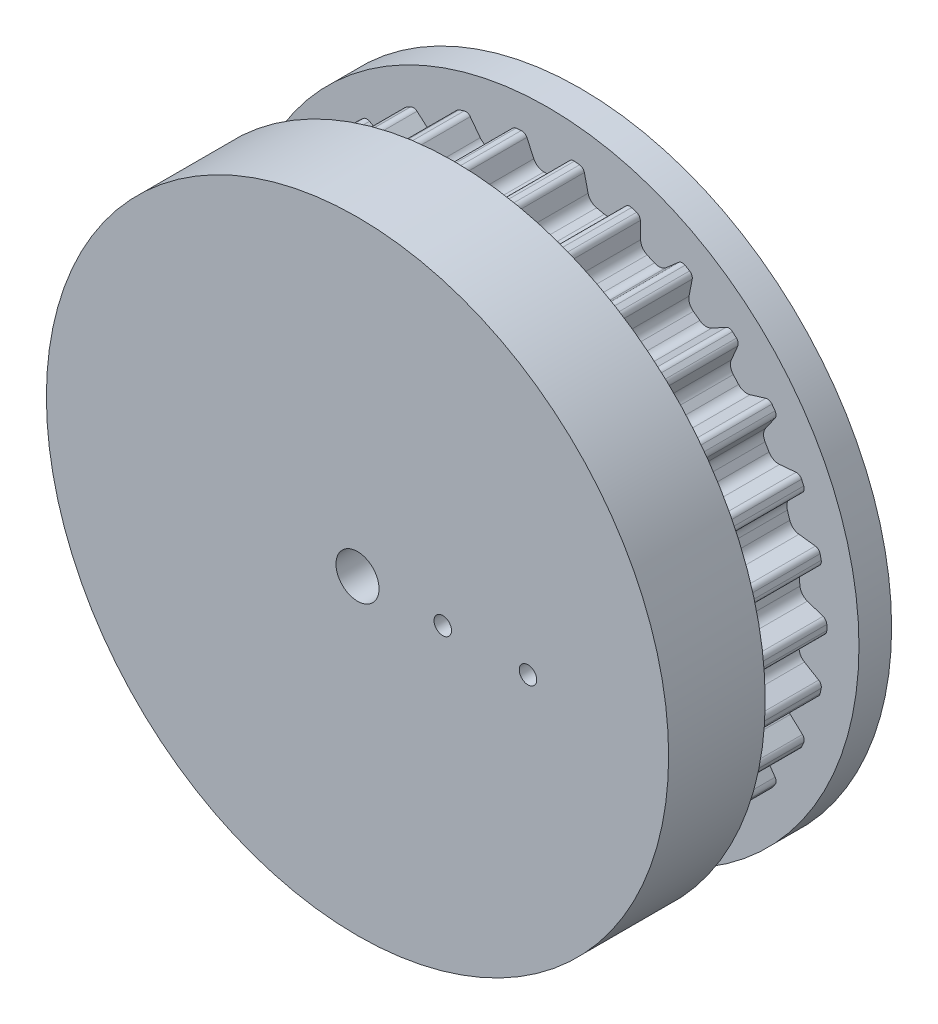
from build123d import *

# Parameters (mm, degrees)
CUT_EXTRUDE1_START       = 15.325
CUT_EXTRUDE1_DEPTH       = 37
FILLET2_R                = 1.298222222
FILLET1_R                = 2.596444444
CIRPATTERN1_COUNT        = 30
FILLET2_OF_CIRPATTERN1_R = 1.298222222
FILLET1_OF_CIRPATTERN1_R = 2.596444444
SKETCH5_R                = 22.54
CUT_EXTRUDE2_DEPTH       = 0.762
CUT_EXTRUDE3_START       = -0.762
SKETCH9_R                = 22.54
CUT_EXTRUDE3_DEPTH       = 0.762
SKETCH11_W               = 111
SKETCH11_H               = 6.35
CUT_EXTRUDE4_DEPTH       = 86.5
BOSS_EXTRUDE1_START      = -52.32
SKETCH12_R               = 20
BOSS_EXTRUDE1_DEPTH      = 52.32
SKETCH13_R               = 73
BOSS_EXTRUDE2_DEPTH      = 15
BOSS_EXTRUDE6_START      = 0.762
SKETCH19_R               = 22.54
SKETCH19_R_2             = 20
BOSS_EXTRUDE6_DEPTH      = 0.762
HOLE2_D                  = 10.1
CUT_EXTRUDE5_REACH       = 117.738
SKETCH22_R               = 2.05


with BuildPart() as part:
    # Sketch10 → Revolve1 (revolve)
    with BuildSketch(Plane(origin=(0, 0, 0), x_dir=(0, 0, -1), z_dir=(1, 0, 0)), mode=Mode.PRIVATE) as revolve1_sk:
        Polygon((-22.985, 20), (29.335, 20), (29.335, 73), (21.675, 73), (21.675, 65.445), (-15.325, 65.445), (-15.325, 73), (-22.985, 73), (-22.985, 55.5), (-29.335, 55.5), (-29.335, 20), align=None)
    revolve(revolve1_sk.sketch.rotate(Axis((0, 0, 22.985), (0, 0, -1)), 90), axis=Axis((0, 0, 22.985), (0, 0, -1)))

    # Sketch3 → Cut-Extrude1 (cut)
    with BuildSketch(Plane.XY.offset(CUT_EXTRUDE1_START)):
        with BuildLine():
            Line((-2.586739752, 59.387151992), (2.586739752, 59.387151992))
            Line((2.586739752, 59.387151992), (5.310909091, 65.229151992))
            ThreePointArc((5.310909091, 65.229151992), (0, 65.445), (-5.310909091, 65.229151992))
            Line((-5.310909091, 65.229151992), (-2.586739752, 59.387151992))
        make_face()
    cut_extrude1 = extrude(amount=-CUT_EXTRUDE1_DEPTH, mode=Mode.SUBTRACT)

    # Fillet2
    fillet2_edges = [part.edges().sort_by_distance(p)[0] for p in [
        (-5.310909091, 65.229151992, -3.175),
        (5.310909091, 65.229151992, -3.175),
    ]]
    fillet(fillet2_edges, radius=FILLET2_R)

    # Fillet1
    fillet1_edges = [part.edges().sort_by_distance(p)[0] for p in [
        (-2.586739752, 59.387151992, -3.175),
        (2.586739752, 59.387151992, -3.175),
    ]]
    fillet(fillet1_edges, radius=FILLET1_R)

    # CirPattern1: Cut-Extrude1 ×30 about axis
    cirpattern1_axis = Axis((0, 0, 0), (0, 0, 1))
    for i in range(1, CIRPATTERN1_COUNT):
        add(cut_extrude1.rotate(cirpattern1_axis, i * 360 / CIRPATTERN1_COUNT), mode=Mode.SUBTRACT)

    # Fillet2 of CirPattern1
    fillet2_of_cirpattern1_edges = [part.edges().sort_by_distance(p)[0] for p in [
        (-18.756756266, 62.69953843, -3.175),
        (-8.367050296, 64.907938608, -3.175),
        (-31.382843188, 57.429654173, -3.175),
        (-21.679329436, 61.749936844, -3.175),
        (-42.637349271, 49.64981845, -3.175),
        (-34.04411785, 55.89316653, -3.175),
        (-52.028398594, 39.700047415, -3.175),
        (-44.921014953, 47.593596634, -3.175),
        (-59.145557238, 28.015193806, -3.175),
        (-53.834648147, 37.213958186, -3.175),
        (-63.677771219, 15.105941796, -3.175),
        (-60.39544889, 25.207891193, -3.175),
        (-65.426961038, 1.536487643, -3.175),
        (-64.316678707, 12.100118393, -3.175),
        (-64.316678707, -12.100118393, -3.175),
        (-65.426961038, -1.536487643, -3.175),
        (-60.39544889, -25.207891193, -3.175),
        (-63.677771219, -15.105941796, -3.175),
        (-53.834648147, -37.213958186, -3.175),
        (-59.145557238, -28.015193806, -3.175),
        (-44.921014953, -47.593596634, -3.175),
        (-52.028398594, -39.700047415, -3.175),
        (-34.04411785, -55.89316653, -3.175),
        (-42.637349271, -49.64981845, -3.175),
        (-21.679329436, -61.749936844, -3.175),
        (-31.382843188, -57.429654173, -3.175),
        (-8.367050296, -64.907938608, -3.175),
        (-18.756756266, -62.69953843, -3.175),
        (5.310909091, -65.229151992, -3.175),
        (-5.310909091, -65.229151992, -3.175),
        (18.756756266, -62.69953843, -3.175),
        (8.367050296, -64.907938608, -3.175),
        (31.382843188, -57.429654173, -3.175),
        (21.679329436, -61.749936844, -3.175),
        (42.637349271, -49.64981845, -3.175),
        (34.04411785, -55.89316653, -3.175),
        (52.028398594, -39.700047415, -3.175),
        (44.921014953, -47.593596634, -3.175),
        (59.145557238, -28.015193806, -3.175),
        (53.834648147, -37.213958186, -3.175),
        (63.677771219, -15.105941796, -3.175),
        (60.39544889, -25.207891193, -3.175),
        (65.426961038, -1.536487643, -3.175),
        (64.316678707, -12.100118393, -3.175),
        (64.316678707, 12.100118393, -3.175),
        (65.426961038, 1.536487643, -3.175),
        (60.39544889, 25.207891193, -3.175),
        (63.677771219, 15.105941796, -3.175),
        (53.834648147, 37.213958186, -3.175),
        (59.145557238, 28.015193806, -3.175),
        (44.921014953, 47.593596634, -3.175),
        (52.028398594, 39.700047415, -3.175),
        (34.04411785, 55.89316653, -3.175),
        (42.637349271, 49.64981845, -3.175),
        (21.679329436, 61.749936844, -3.175),
        (31.382843188, 57.429654173, -3.175),
        (8.367050296, 64.907938608, -3.175),
        (18.756756266, 62.69953843, -3.175),
    ]]
    fillet(fillet2_of_cirpattern1_edges, radius=FILLET2_OF_CIRPATTERN1_R)

    # Fillet1 of CirPattern1
    fillet1_of_cirpattern1_edges = [part.edges().sort_by_distance(p)[0] for p in [
        (-14.877496466, 57.5515868, -3.175),
        (-9.817069901, 58.627213671, -3.175),
        (-26.518035194, 53.200741102, -3.175),
        (-21.791826493, 55.304984788, -3.175),
        (-36.999608536, 46.524767732, -3.175),
        (-32.814175697, 49.565662687, -3.175),
        (-45.864121442, 37.815438761, -3.175),
        (-42.402387964, 41.660083284, -3.175),
        (-52.72415216, 27.453393658, -3.175),
        (-50.137412408, 31.933758334, -3.175),
        (-57.27988443, 15.891503516, -3.175),
        (-55.681191343, 20.81177491, -3.175),
        (-59.332210891, 3.635078415, -3.175),
        (-58.791435029, 8.780217057, -3.175),
        (-58.791435029, -8.780217057, -3.175),
        (-59.332210891, -3.635078415, -3.175),
        (-55.681191343, -20.81177491, -3.175),
        (-57.27988443, -15.891503516, -3.175),
        (-50.137412408, -31.933758334, -3.175),
        (-52.72415216, -27.453393658, -3.175),
        (-42.402387964, -41.660083284, -3.175),
        (-45.864121442, -37.815438761, -3.175),
        (-32.814175697, -49.565662687, -3.175),
        (-36.999608536, -46.524767732, -3.175),
        (-21.791826493, -55.304984788, -3.175),
        (-26.518035194, -53.200741102, -3.175),
        (-9.817069901, -58.627213671, -3.175),
        (-14.877496466, -57.5515868, -3.175),
        (2.586739752, -59.387151992, -3.175),
        (-2.586739752, -59.387151992, -3.175),
        (14.877496466, -57.5515868, -3.175),
        (9.817069901, -58.627213671, -3.175),
        (26.518035194, -53.200741102, -3.175),
        (21.791826493, -55.304984788, -3.175),
        (36.999608536, -46.524767732, -3.175),
        (32.814175697, -49.565662687, -3.175),
        (45.864121442, -37.815438761, -3.175),
        (42.402387964, -41.660083284, -3.175),
        (52.72415216, -27.453393658, -3.175),
        (50.137412408, -31.933758334, -3.175),
        (57.27988443, -15.891503516, -3.175),
        (55.681191343, -20.81177491, -3.175),
        (59.332210891, -3.635078415, -3.175),
        (58.791435029, -8.780217057, -3.175),
        (58.791435029, 8.780217057, -3.175),
        (59.332210891, 3.635078415, -3.175),
        (55.681191343, 20.81177491, -3.175),
        (57.27988443, 15.891503516, -3.175),
        (50.137412408, 31.933758334, -3.175),
        (52.72415216, 27.453393658, -3.175),
        (42.402387964, 41.660083284, -3.175),
        (45.864121442, 37.815438761, -3.175),
        (32.814175697, 49.565662687, -3.175),
        (36.999608536, 46.524767732, -3.175),
        (21.791826493, 55.304984788, -3.175),
        (26.518035194, 53.200741102, -3.175),
        (9.817069901, 58.627213671, -3.175),
        (14.877496466, 57.5515868, -3.175),
    ]]
    fillet(fillet1_of_cirpattern1_edges, radius=FILLET1_OF_CIRPATTERN1_R)

    # Sketch5 → Cut-Extrude2 (cut)
    with BuildSketch(Plane.XY.offset(-29.335)):
        with Locations(Location((0, 0, 0), (0, 0, 180))):
            Circle(SKETCH5_R)
    extrude(amount=CUT_EXTRUDE2_DEPTH, mode=Mode.SUBTRACT)

    # Sketch9 → Cut-Extrude3 (cut)
    with BuildSketch(Plane.XY.offset(29.335).offset(CUT_EXTRUDE3_START)):
        with Locations(Location((0, 0, 0), (0, 0, 180))):
            Circle(SKETCH9_R)
    extrude(amount=CUT_EXTRUDE3_DEPTH, mode=Mode.SUBTRACT)

    # Sketch11 → Cut-Extrude4 (cut, symmetric)
    with BuildSketch(Plane(origin=(0, 0, 0), x_dir=(1, 0, 0), z_dir=(0, 1, 0))):
        with Locations((0, -26.16)):
            Rectangle(SKETCH11_W, SKETCH11_H)
    extrude(amount=CUT_EXTRUDE4_DEPTH, both=True, mode=Mode.SUBTRACT)

    # Sketch12 → Boss-Extrude1 (add)
    with BuildSketch(Plane.XY.offset(22.985).offset(BOSS_EXTRUDE1_START)):
        Circle(SKETCH12_R)
    extrude(amount=BOSS_EXTRUDE1_DEPTH)

    # Sketch13 → Boss-Extrude2 (add)
    with BuildSketch(Plane(origin=(0, 0, 15.325), x_dir=(-1, 0, 0), z_dir=(0, 0, -1))):
        with Locations(Location((0, 0, 0), (0, 0, 180))):
            Circle(SKETCH13_R)
    extrude(amount=BOSS_EXTRUDE2_DEPTH)

    # Sketch19 → Boss-Extrude6 (add)
    with BuildSketch(Plane(origin=(0, 0, -28.573), x_dir=(-1, 0, 0), z_dir=(0, 0, -1)).offset(BOSS_EXTRUDE6_START)):
        Circle(SKETCH19_R)
        Circle(SKETCH19_R_2, mode=Mode.SUBTRACT)
    extrude(amount=-BOSS_EXTRUDE6_DEPTH)

    # Hole2 (through all)
    with Locations(Plane.XY.offset(22.985)):
        with Locations((0, 0)):
            Hole(HOLE2_D / 2)

    # Sketch22 → Cut-Extrude5 (cut, up to next)
    with BuildSketch(Plane.XY.offset(22.985), mode=Mode.PRIVATE) as cut_extrude5_sk1:
        with Locations((20, 0)):
            Circle(SKETCH22_R)
    cut_extrude5_tool1 = extrude(cut_extrude5_sk1.sketch, amount=-CUT_EXTRUDE5_REACH, mode=Mode.PRIVATE) & part.part
    # Sketch22 → Cut-Extrude5 (cut, up to next)
    with BuildSketch(Plane.XY.offset(22.985), mode=Mode.PRIVATE) as cut_extrude5_sk2:
        with Locations((40, 0)):
            Circle(SKETCH22_R)
    cut_extrude5_tool2 = extrude(cut_extrude5_sk2.sketch, amount=-CUT_EXTRUDE5_REACH, mode=Mode.PRIVATE) & part.part
    add(cut_extrude5_tool1.solids().sort_by_distance((20, 0, 22.985))[0], mode=Mode.SUBTRACT)
    add(cut_extrude5_tool2.solids().sort_by_distance((40, 0, 22.985))[0], mode=Mode.SUBTRACT)


solid = part.part
